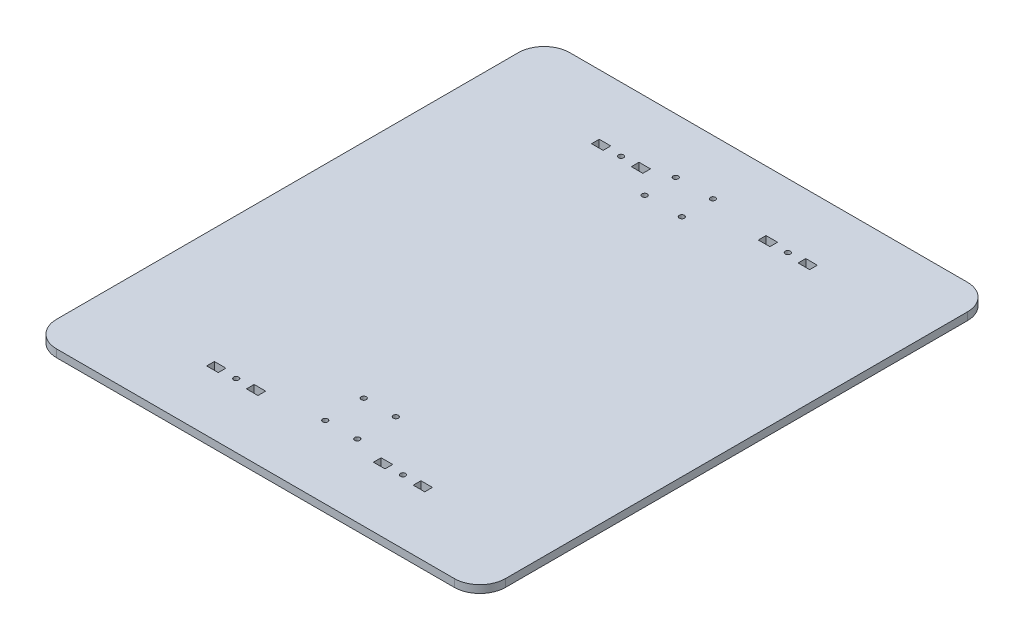
from build123d import *

# Parameters (mm, degrees)
BOSS_EXTRUDE1_DEPTH = 6
SKETCH2_R           = 2
CUT_EXTRUDE1_DEPTH  = 10
SKETCH3_R           = 2
SKETCH3_W           = 9
SKETCH3_H           = 6
CUT_EXTRUDE5_DEPTH  = 6
SKETCH4_R           = 2
CUT_EXTRUDE6_DEPTH  = 24


with BuildPart() as part:
    # Sketch1 → Boss-Extrude1 (new body)
    with BuildSketch(Plane(origin=(0, 0, 0), x_dir=(1, 0, 0), z_dir=(0, 1, 0))):
        with BuildLine():
            Line((-155, -200), (155, -200))
            ThreePointArc((155, -200), (169.142135624, -194.142135624), (175, -180))
            Line((175, -180), (175, 180))
            ThreePointArc((175, 180), (169.142135624, 194.142135624), (155, 200))
            Line((155, 200), (-155, 200))
            ThreePointArc((-155, 200), (-169.142135624, 194.142135624), (-175, 180))
            Line((-175, 180), (-175, -180))
            ThreePointArc((-175, -180), (-169.142135624, -194.142135624), (-155, -200))
        make_face()
    extrude(amount=BOSS_EXTRUDE1_DEPTH)

    # Sketch2 → Cut-Extrude1 (cut)
    with BuildSketch(Plane(origin=(0, 6, 0), x_dir=(1, 0, 0), z_dir=(0, 1, 0))):
        with Locations((-2, -113.559557499)):
            Circle(SKETCH2_R)
        with Locations((23, -113.559557499)):
            Circle(SKETCH2_R)
        with Locations((23, -143.559557499)):
            Circle(SKETCH2_R)
        with Locations((-2, -143.559557499)):
            Circle(SKETCH2_R)
    extrude(amount=-CUT_EXTRUDE1_DEPTH, mode=Mode.SUBTRACT)

    # Sketch3 → Cut-Extrude5 (cut)
    with BuildSketch(Plane(origin=(0, 6, 0), x_dir=(1, 0, 0), z_dir=(0, 1, 0))):
        with Locations((-65, 150)):
            Circle(SKETCH3_R)
        with Locations((65, 150)):
            Circle(SKETCH3_R)
        with Locations((65, -150)):
            Circle(SKETCH3_R)
        with Locations((-65, -150)):
            Circle(SKETCH3_R)
        with Locations((-49.5, 150)):
            Rectangle(SKETCH3_W, SKETCH3_H)
        with Locations((-80.5, 150)):
            Rectangle(SKETCH3_W, SKETCH3_H)
        with Locations((49.5, 150)):
            Rectangle(SKETCH3_W, SKETCH3_H)
        with Locations((80.5, 150)):
            Rectangle(SKETCH3_W, SKETCH3_H)
        with Locations((80.5, -150)):
            Rectangle(SKETCH3_W, SKETCH3_H)
        with Locations((49.5, -150)):
            Rectangle(SKETCH3_W, SKETCH3_H)
        with Locations((-49.5, -150)):
            Rectangle(SKETCH3_W, SKETCH3_H)
        with Locations((-80.5, -150)):
            Rectangle(SKETCH3_W, SKETCH3_H)
    extrude(amount=-CUT_EXTRUDE5_DEPTH, mode=Mode.SUBTRACT)

    # Sketch4 → Cut-Extrude6 (cut)
    with BuildSketch(Plane(origin=(0, 6, 0), x_dir=(1, 0, 0), z_dir=(0, 1, 0))):
        with Locations((-29.4825, 157.11)):
            Circle(SKETCH4_R)
        with Locations((-0.5175, 157.11)):
            Circle(SKETCH4_R)
        with Locations((-0.5175, 132.89)):
            Circle(SKETCH4_R)
        with Locations((-29.4825, 132.89)):
            Circle(SKETCH4_R)
    extrude(amount=-CUT_EXTRUDE6_DEPTH, mode=Mode.SUBTRACT)


solid = part.part
